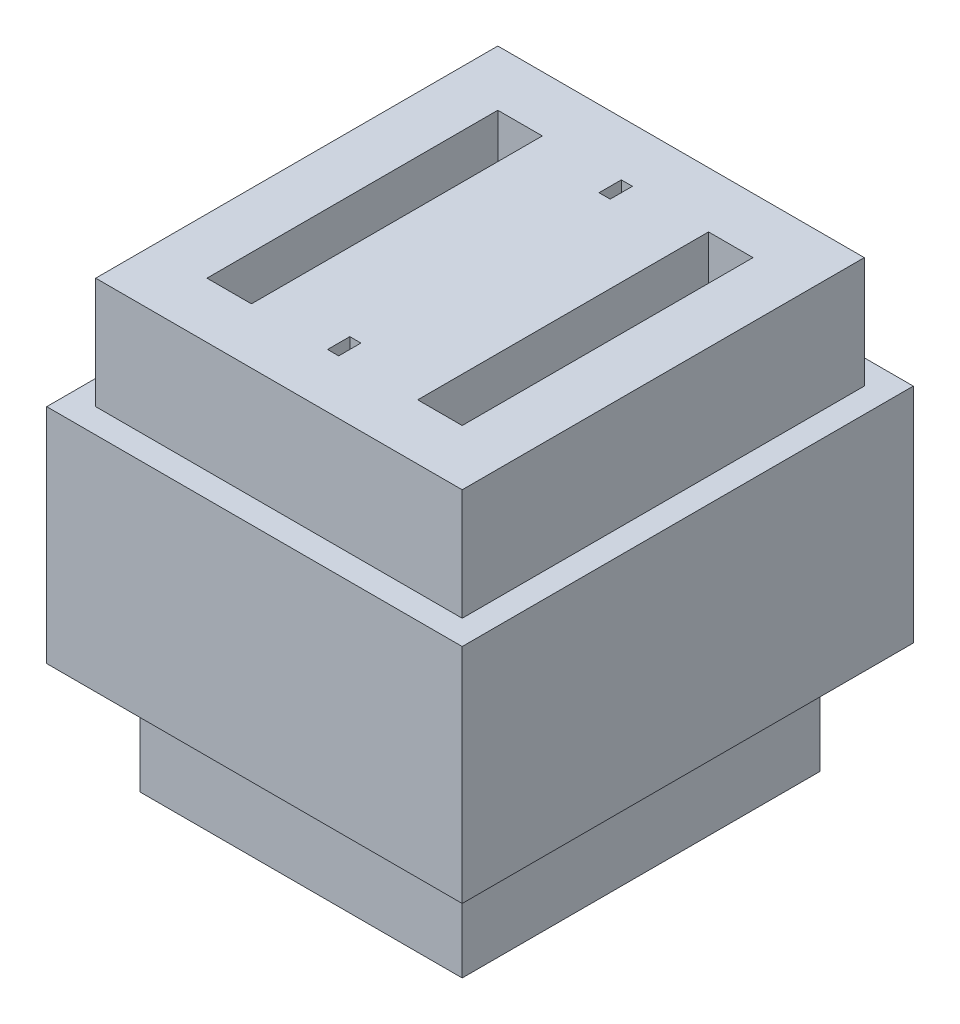
from build123d import *

# Parameters (mm, degrees)
SKETCH1_W           = 18.67
SKETCH1_H           = 20.27
BOSS_EXTRUDE1_DEPTH = 10
SKETCH2_W           = 18.67
SKETCH2_H           = 20.27
SKETCH2_W_2         = 16.47
SKETCH2_H_2         = 18.07
CUT_EXTRUDE1_DEPTH  = 5
SKETCH7_W           = 18.67
SKETCH7_H           = 20.27
SKETCH7_W_2         = 14.47
SKETCH7_H_2         = 16.07
CUT_EXTRUDE5_DEPTH  = 5
SKETCH3_W           = 10.47
SKETCH3_H           = 12.07
CUT_EXTRUDE2_DEPTH  = 16
CUT_EXTRUDE3_START  = -10
SKETCH4_W           = 2
SKETCH4_H           = 13.07
CUT_EXTRUDE3_DEPTH  = 10
SKETCH6_W           = 3.5
SKETCH6_H           = 12.07
BOSS_EXTRUDE2_DEPTH = 5
SKETCH5_W           = 0.5
SKETCH5_H           = 1
CUT_EXTRUDE4_DEPTH  = 7


with BuildPart() as part:
    # Sketch1 → Boss-Extrude1 (new body, symmetric)
    with BuildSketch(Plane(origin=(0, 0, 0), x_dir=(1, 0, 0), z_dir=(0, 1, 0))):
        Rectangle(SKETCH1_W, SKETCH1_H)
    extrude(amount=BOSS_EXTRUDE1_DEPTH, both=True)

    # Sketch2 → Cut-Extrude1 (cut)
    with BuildSketch(Plane(origin=(0, 10, 0), x_dir=(1, 0, 0), z_dir=(0, 1, 0))):
        Rectangle(SKETCH2_W, SKETCH2_H)
        Rectangle(SKETCH2_W_2, SKETCH2_H_2, mode=Mode.SUBTRACT)
    extrude(amount=-CUT_EXTRUDE1_DEPTH, mode=Mode.SUBTRACT)

    # Sketch7 → Cut-Extrude5 (cut)
    with BuildSketch(Plane.XZ.offset(10)):
        Rectangle(SKETCH7_W, SKETCH7_H)
        Rectangle(SKETCH7_W_2, SKETCH7_H_2, mode=Mode.SUBTRACT)
    extrude(amount=-CUT_EXTRUDE5_DEPTH, mode=Mode.SUBTRACT)

    # Sketch3 → Cut-Extrude2 (cut)
    with BuildSketch(Plane.XZ.offset(10)):
        Rectangle(SKETCH3_W, SKETCH3_H)
    extrude(amount=-CUT_EXTRUDE2_DEPTH, mode=Mode.SUBTRACT)

    # Sketch4 → Cut-Extrude3 (cut)
    with BuildSketch(Plane(origin=(0, 10, 0), x_dir=(1, 0, 0), z_dir=(0, 1, 0)).offset(CUT_EXTRUDE3_START)):
        with Locations((-4.735, 0)):
            Rectangle(SKETCH4_W, SKETCH4_H)
        with Locations((4.735, 0)):
            Rectangle(SKETCH4_W, SKETCH4_H)
    extrude(amount=CUT_EXTRUDE3_DEPTH, mode=Mode.SUBTRACT)

    # Sketch6 → Boss-Extrude2 (add)
    with BuildSketch(Plane.XZ.offset(-6)):
        Rectangle(SKETCH6_W, SKETCH6_H)
    extrude(amount=BOSS_EXTRUDE2_DEPTH)

    # Sketch5 → Cut-Extrude4 (cut)
    with BuildSketch(Plane(origin=(0, 10, 0), x_dir=(1, 0, 0), z_dir=(0, 1, 0))):
        with Locations((0, -6.1)):
            Rectangle(SKETCH5_W, SKETCH5_H)
        with Locations((0, 6.1)):
            Rectangle(SKETCH5_W, SKETCH5_H)
    extrude(amount=-CUT_EXTRUDE4_DEPTH, mode=Mode.SUBTRACT)


solid = part.part
